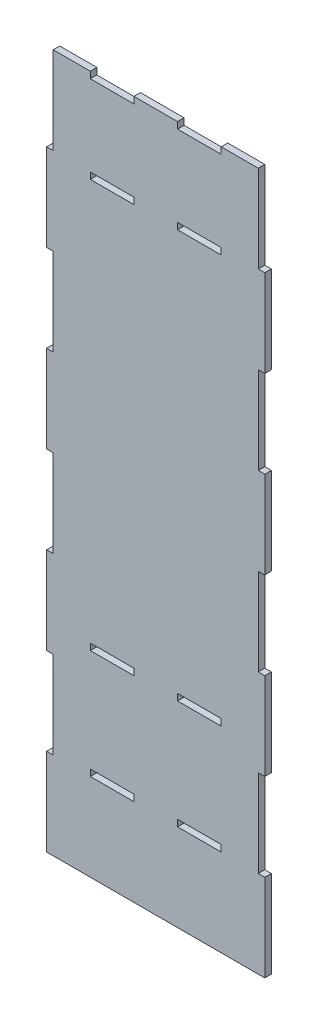
from build123d import *

# Parameters (mm, degrees)
SKETCH_1_W      = 20
SKETCH_1_H      = 3
SKETCH_1_H_2    = 2.958752526
EXTRUDE_1_DEPTH = 3


with BuildPart() as part:
    # 草图1 → 凸台-拉伸1 (new body)
    with BuildSketch(Plane.XY):
        Polygon((50, -50.59602649), (50, -10.59602649), (47, -10.59602649), (47, 29.40397351), (50, 29.40397351), (50, 69.40397351), (47, 69.40397351), (47, 109.40397351), (50, 109.40397351), (50, 149.40397351), (47, 149.40397351), (47, 189.40397351), (50, 189.40397351), (50, 229.40397351), (47, 229.40397351), (47, 269.40397351), (30, 269.40397351), (30, 266.40397351), (10, 266.40397351), (10, 269.40397351), (-10, 269.40397351), (-10, 266.40397351), (-30, 266.40397351), (-30, 269.40397351), (-47, 269.40397351), (-47, 229.40397351), (-50, 229.40397351), (-50, 189.40397351), (-47, 189.40397351), (-47, 149.40397351), (-50, 149.40397351), (-50, 109.40397351), (-47, 109.40397351), (-47, 69.40397351), (-50, 69.40397351), (-50, 29.40397351), (-47, 29.40397351), (-47, -10.59602649), (-50, -10.59602649), (-50, -50.59602649), align=None)
        with Locations((-20, 40.90397351)):
            Rectangle(SKETCH_1_W, SKETCH_1_H, mode=Mode.SUBTRACT)
        with Locations((-20, -9.09602649)):
            Rectangle(SKETCH_1_W, SKETCH_1_H, mode=Mode.SUBTRACT)
        with Locations((20, 40.90397351)):
            Rectangle(SKETCH_1_W, SKETCH_1_H, mode=Mode.SUBTRACT)
        with Locations((20, -9.09602649)):
            Rectangle(SKETCH_1_W, SKETCH_1_H, mode=Mode.SUBTRACT)
        with Locations((-20, 227.924597247)):
            Rectangle(SKETCH_1_W, SKETCH_1_H_2, mode=Mode.SUBTRACT)
        with Locations((20, 227.924597247)):
            Rectangle(SKETCH_1_W, SKETCH_1_H_2, mode=Mode.SUBTRACT)
    extrude(amount=EXTRUDE_1_DEPTH)


solid = part.part
